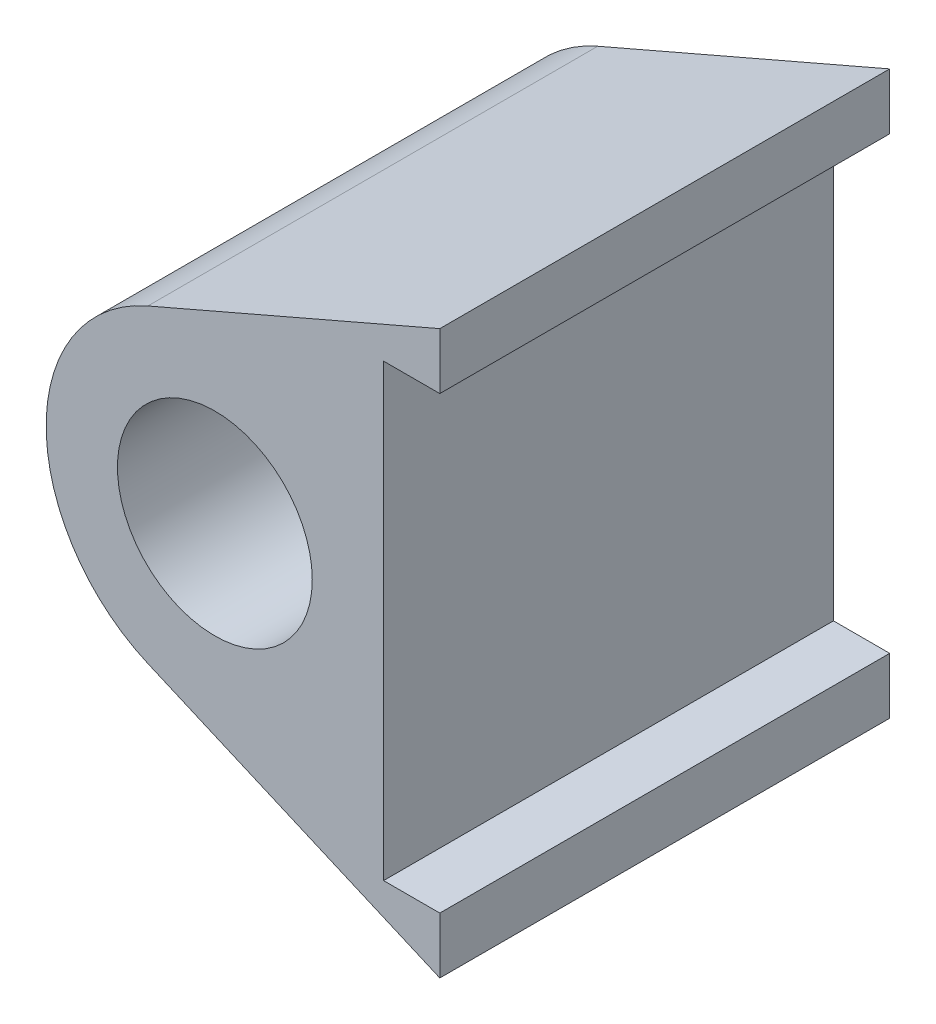
from build123d import *

# Parameters (mm, degrees)
SKETCH1_R           = 10.99947
BOSS_EXTRUDE1_DEPTH = 50.8


with BuildPart() as part:
    # Sketch1 → Boss-Extrude1 (new body)
    with BuildSketch(Plane.XY):
        with BuildLine():
            Line((19.05, -25.4), (19.05, 25.4))
            Line((19.05, 25.4), (25.4, 25.4))
            Line((25.4, 25.4), (25.4, 31.75))
            Line((25.4, 31.75), (-7.56622847, 17.482982776))
            ThreePointArc((-7.56622847, 17.482982776), (-19.05, 0), (-7.56622847, -17.482982776))
            Line((-7.56622847, -17.482982776), (25.4, -31.75))
            Line((25.4, -31.75), (25.4, -25.4))
            Line((25.4, -25.4), (19.05, -25.4))
        make_face()
        Circle(SKETCH1_R, mode=Mode.SUBTRACT)
    extrude(amount=BOSS_EXTRUDE1_DEPTH)


solid = part.part
